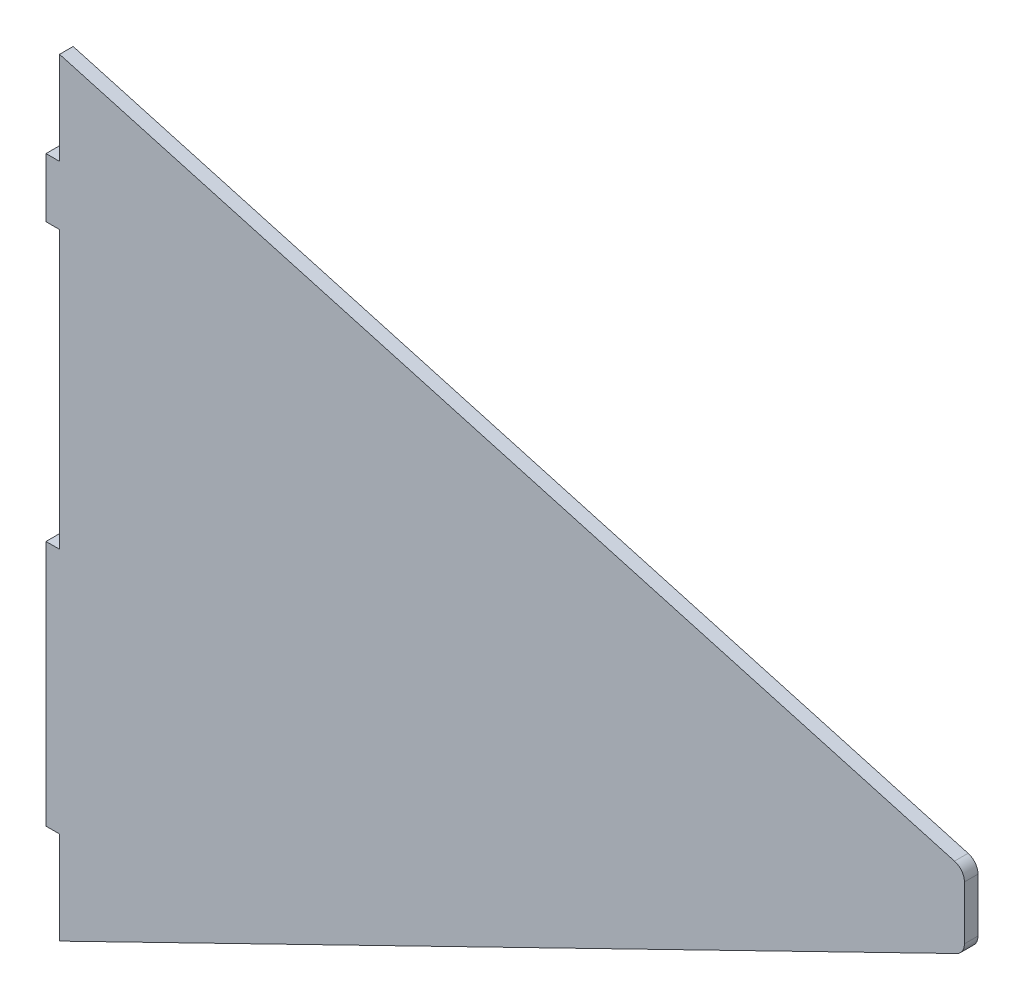
from build123d import *

# Parameters (mm, degrees)
BOSS_EXTRUDE1_DEPTH = 3
FILLET1_R           = 3


with BuildPart() as part:
    # Sketch1 → Boss-Extrude1 (new body)
    with BuildSketch(Plane.XY):
        Polygon((203, -32.85), (3, 23.3), (3, 2.8), (0, 2.8), (0, -10.25), (3, -10.25), (3, -71.45), (0, -71.45), (0, -125.95), (3, -125.95), (3, -146.45), (203, -48.85), align=None)
    extrude(amount=BOSS_EXTRUDE1_DEPTH)

    # Fillet1
    fillet1_edges = [part.edges().sort_by_distance(p)[0] for p in [
        (203, -48.85, 1.5),
        (203, -32.85, 1.5),
    ]]
    fillet(fillet1_edges, radius=FILLET1_R)


solid = part.part
